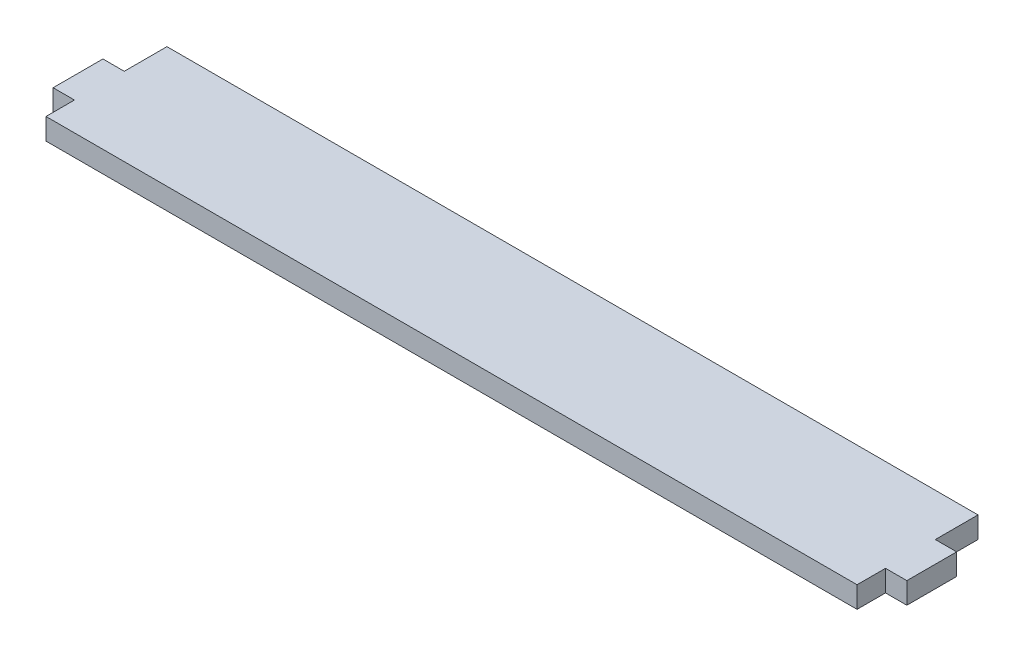
from build123d import *

# Parameters (mm, degrees)
SALIENTE_EXTRUIR1_DEPTH = 3


with BuildPart() as part:
    # Croquis1 → Saliente-Extruir1 (new body)
    with BuildSketch(Plane(origin=(0, 0, 0), x_dir=(1, 0, 0), z_dir=(0, 1, 0))):
        Polygon((-57, 2.5), (-60, 2.5), (-60, -4.5), (-57, -4.5), (-57, -8.5), (57, -8.5), (57, -4.5), (60, -4.5), (60, 2.5), (57, 2.5), (57, 8.5), (-57, 8.5), align=None)
    extrude(amount=SALIENTE_EXTRUIR1_DEPTH)


solid = part.part
